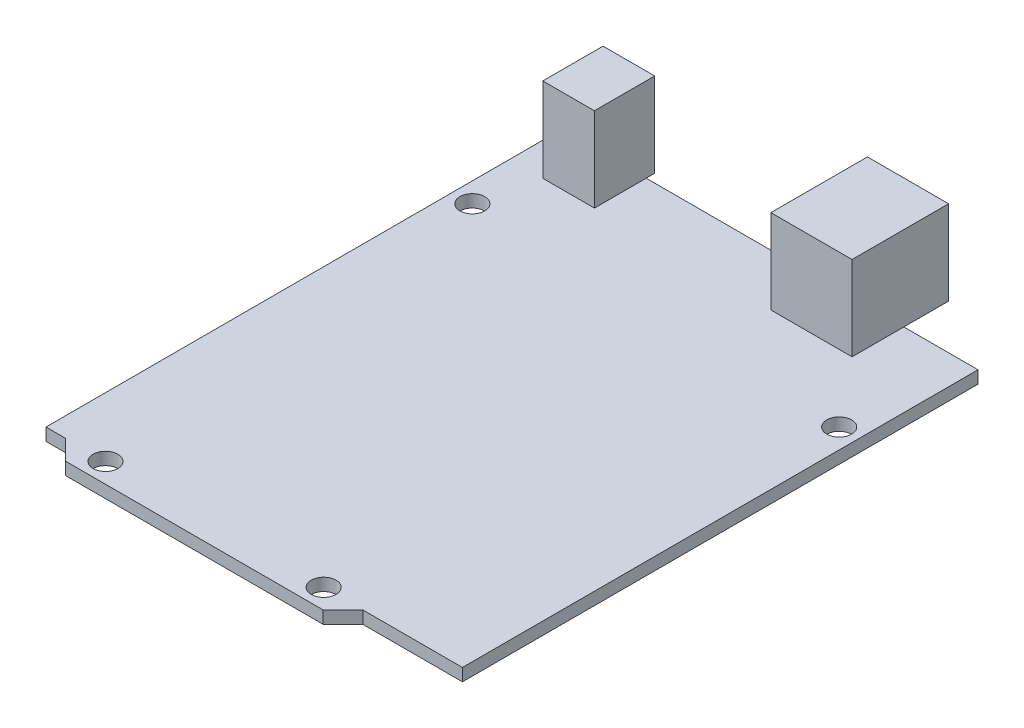
from build123d import *

# Parameters (mm, degrees)
BOSS_EXTRUDE1_DEPTH = 1.6
SKETCH2_W           = 6.615656004
SKETCH2_H           = 7.718265338
SKETCH2_W_2         = 10.396030864
SKETCH2_H_2         = 12.364976103
BOSS_EXTRUDE2_DEPTH = 10.8
SKETCH3_R           = 1.5875
CUT_EXTRUDE1_DEPTH  = 2.6


with BuildPart() as part:
    # Sketch1 → Boss-Extrude1 (new body)
    with BuildSketch(Plane(origin=(0, 0, 0), x_dir=(1, 0, 0), z_dir=(0, 1, 0))):
        Polygon((0, 68.58), (0, 2.54), (2.5, 2.54), (5.04, 0), (38.04, 0), (40.58, 2.54), (53.34, 2.54), (53.34, 68.58), align=None)
    extrude(amount=BOSS_EXTRUDE1_DEPTH)

    # Sketch2 → Boss-Extrude2 (add)
    with BuildSketch(Plane(origin=(0, 1.6, 0), x_dir=(1, 0, 0), z_dir=(0, 1, 0))):
        with Locations((7.533094465, 65.806229304)):
            Rectangle(SKETCH2_W, SKETCH2_H)
        with Locations((38.642429245, 68.129584686)):
            Rectangle(SKETCH2_W_2, SKETCH2_H_2)
    extrude(amount=BOSS_EXTRUDE2_DEPTH)

    # Sketch3 → Cut-Extrude1 (cut, through all)
    with BuildSketch(Plane(origin=(0, 1.6, 0), x_dir=(1, 0, 0), z_dir=(0, 1, 0))):
        with Locations((7.62, 2.54)):
            Circle(SKETCH3_R)
        with Locations((35.56, 2.54)):
            Circle(SKETCH3_R)
        with Locations((50.8, 53.34)):
            Circle(SKETCH3_R)
        with Locations((2.54, 54.61)):
            Circle(SKETCH3_R)
    extrude(amount=-CUT_EXTRUDE1_DEPTH, mode=Mode.SUBTRACT)


solid = part.part
